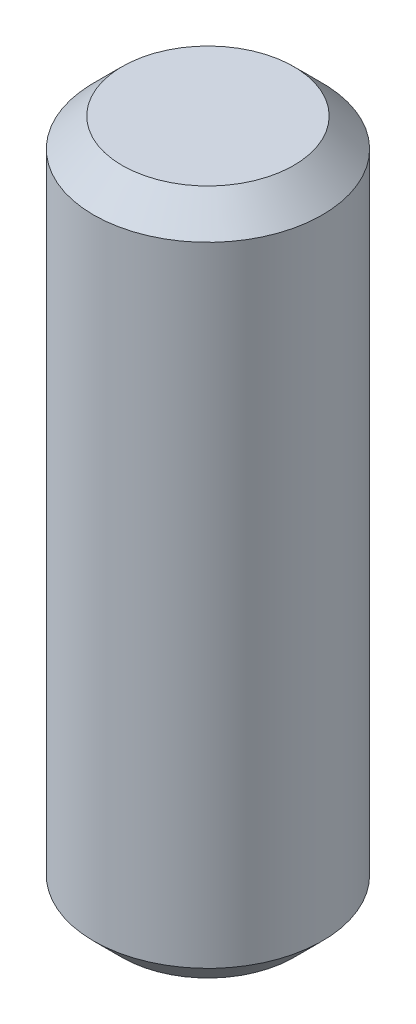
from build123d import *

# Parameters (mm, degrees)
SKETCH1_R           = 2
BOSS_EXTRUDE1_DEPTH = 12
CHAMFER1_SIZE       = 0.5


with BuildPart() as part:
    # Sketch1 → Boss-Extrude1 (new body)
    with BuildSketch(Plane(origin=(0, 0, 0), x_dir=(1, 0, 0), z_dir=(0, 1, 0))):
        Circle(SKETCH1_R)
    extrude(amount=BOSS_EXTRUDE1_DEPTH)

    # Chamfer1
    chamfer1_edges = [part.edges().sort_by_distance(p)[0] for p in [
        (-2, 0, 0),
        (-2, 12, 0),
    ]]
    chamfer(chamfer1_edges, length=CHAMFER1_SIZE)


solid = part.part
